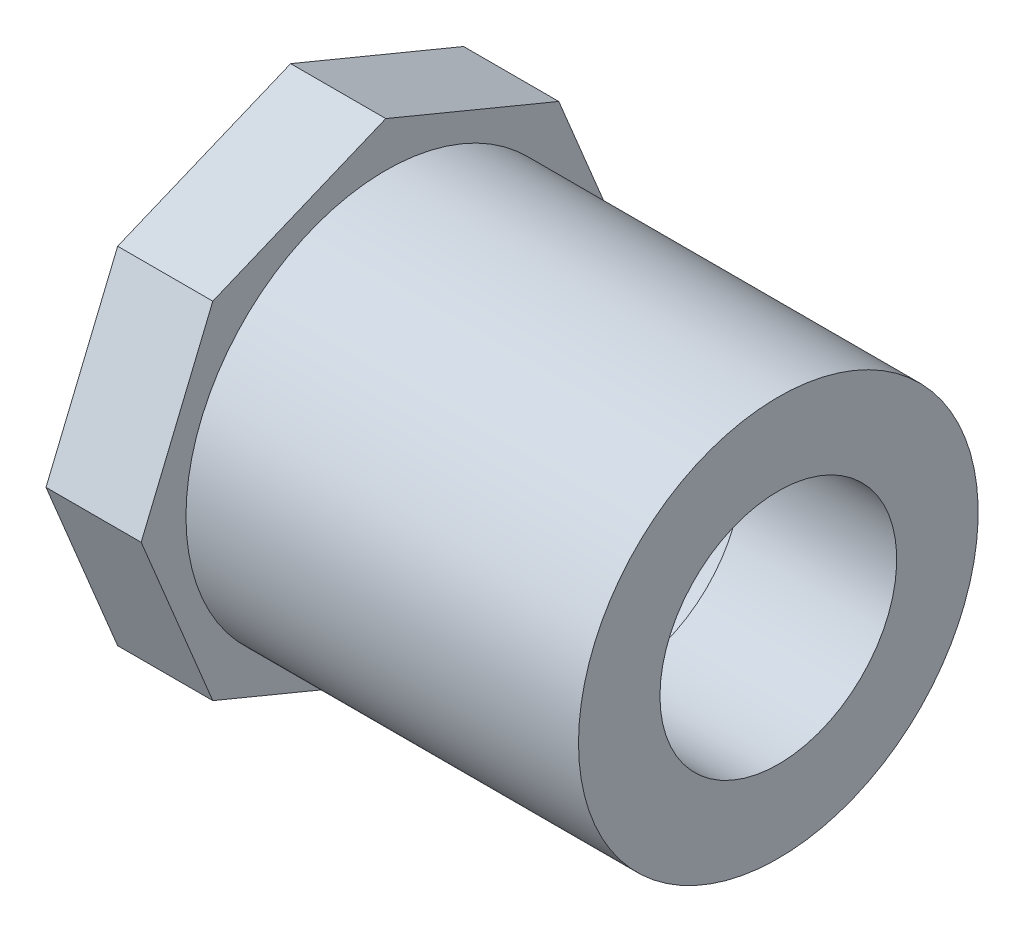
from build123d import *

# Parameters (mm, degrees)
SKETCH2_R           = 10.7696
BOSS_EXTRUDE1_DEPTH = 6.35


with BuildPart() as part:
    # Sketch1 → Revolve1 (revolve)
    with BuildSketch(Plane.XY):
        Polygon((-32.54375, -13.335), (0, -13.335), (0, -7.8994), (-10.31875, -7.8994), (-10.31875, -10.6172), (-32.54375, -10.7696), align=None)
    revolve(axis=Axis((-32.54375, 0, 0), (1, 0, 0)))

    # Sketch2 → Boss-Extrude1 (add)
    with BuildSketch(Plane.ZY.offset(32.54375)):
        Polygon((16.323827371, 0), (11.542689029, 11.542689029), (0, 16.323827371), (-11.542689029, 11.542689029), (-16.323827371, 0), (-11.542689029, -11.542689029), (0, -16.323827371), (11.542689029, -11.542689029), align=None)
        Circle(SKETCH2_R, mode=Mode.SUBTRACT)
    extrude(amount=-BOSS_EXTRUDE1_DEPTH)


solid = part.part
